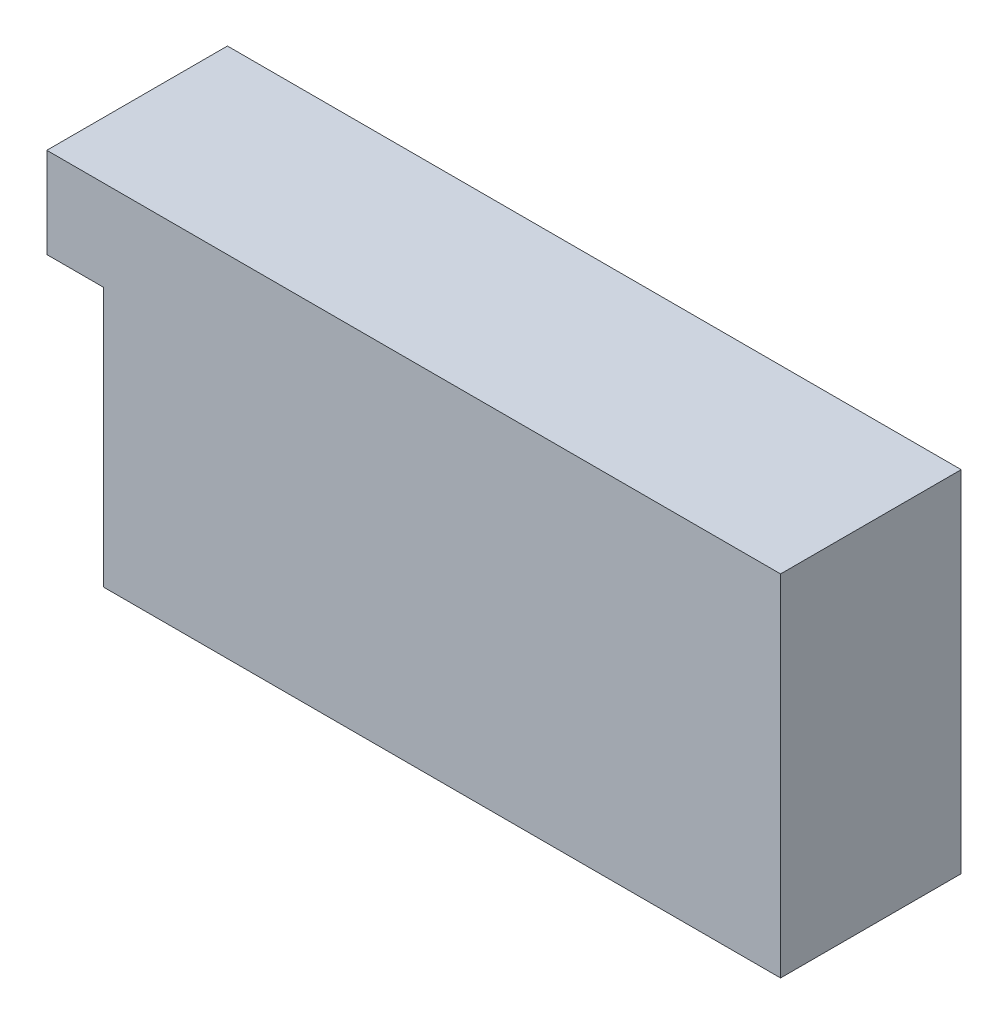
from build123d import *

# Parameters (mm, degrees)
SKETCH1_W           = 60
SKETCH1_H           = 31
BOSS_EXTRUDE1_DEPTH = 16
SKETCH2_W           = 16
SKETCH2_H           = 8
BOSS_EXTRUDE2_DEPTH = 5


with BuildPart() as part:
    # Sketch1 → Boss-Extrude1 (new body)
    with BuildSketch(Plane.XY):
        with Locations((30, 15.5)):
            Rectangle(SKETCH1_W, SKETCH1_H)
    extrude(amount=BOSS_EXTRUDE1_DEPTH)

    # Sketch2 → Boss-Extrude2 (add)
    with BuildSketch(Plane.ZY):
        with Locations((8, 27)):
            Rectangle(SKETCH2_W, SKETCH2_H)
    extrude(amount=BOSS_EXTRUDE2_DEPTH)


solid = part.part
